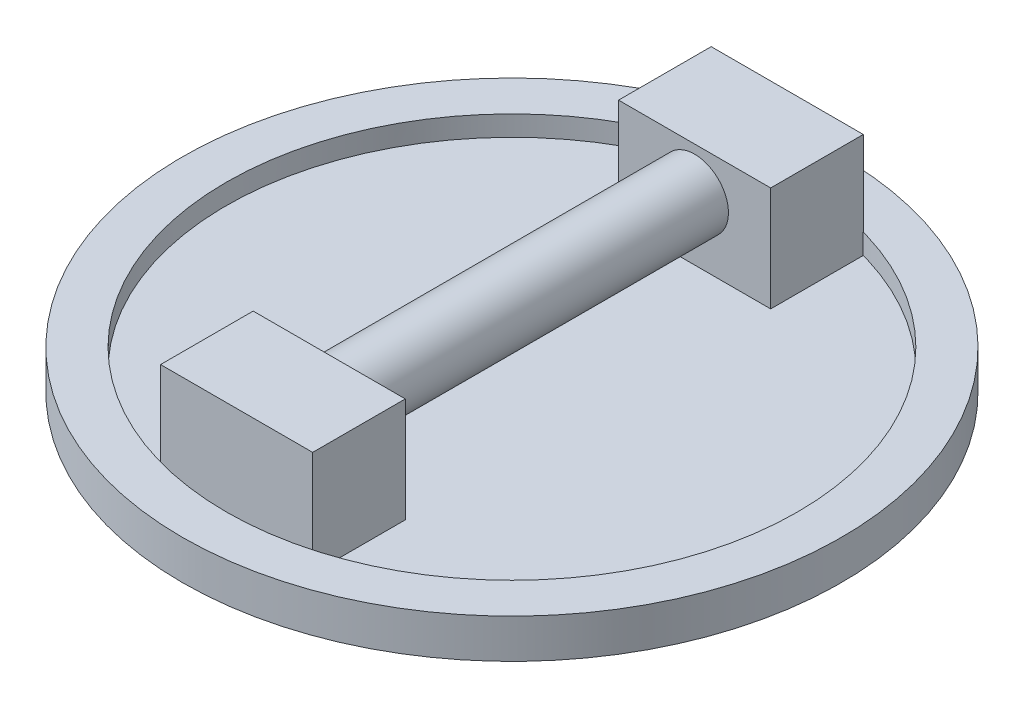
from build123d import *

# Parameters (mm, degrees)
SKETCH1_R             = 123.825
SKETCH1_R_2           = 107.315
BOSS_EXTRUDE1_DEPTH   = 14.732
SKETCH2_R             = 107.315
BOSS_EXTRUDE2_DEPTH   = 7.112
SKETCH3_W             = 57.15
SKETCH3_H             = 34.798
BOSS_EXTRUDE9_DEPTH   = 39.37
BOSS_EXTRUDE9_2_DEPTH = 39.37
SKETCH4_R             = 12.7
BOSS_EXTRUDE10_DEPTH  = 137.285402


with BuildPart() as part:
    # Sketch1 → Boss-Extrude1 (new body)
    with BuildSketch(Plane(origin=(0, 0, 0), x_dir=(1, 0, 0), z_dir=(0, 1, 0))):
        Circle(SKETCH1_R)
        Circle(SKETCH1_R_2, mode=Mode.SUBTRACT)
    extrude(amount=BOSS_EXTRUDE1_DEPTH)

    # Sketch2 → Boss-Extrude2 (add)
    with BuildSketch(Plane.XZ):
        Circle(SKETCH2_R)
    extrude(amount=-BOSS_EXTRUDE2_DEPTH)


with BuildPart() as body_2:
    # Sketch3 → Boss-Extrude9 (new body)
    with BuildSketch(Plane(origin=(0, 7.112, 0), x_dir=(1, 0, 0), z_dir=(0, 1, 0))):
        with Locations((0, -86.041700887)):
            Rectangle(SKETCH3_W, SKETCH3_H)
    extrude(amount=BOSS_EXTRUDE9_DEPTH)



with BuildPart() as body_3:
    # Sketch3 → Boss-Extrude9 2 (new body)
    with BuildSketch(Plane(origin=(0, 7.112, 0), x_dir=(1, 0, 0), z_dir=(0, 1, 0))):
        with Locations((0, 86.041700887)):
            Rectangle(SKETCH3_W, SKETCH3_H)
    extrude(amount=BOSS_EXTRUDE9_2_DEPTH)


with BuildPart() as body_2_1:
    add(body_2.part)

    add(body_3.part)  # Boss-Extrude10 merges body 3
    # Sketch4 → Boss-Extrude10 (add)
    with BuildSketch(Plane.XY.offset(-68.642700887)):
        with Locations((0, 30.48)):
            Circle(SKETCH4_R)
    extrude(amount=BOSS_EXTRUDE10_DEPTH)


solid = Compound([part.part, body_2_1.part])
